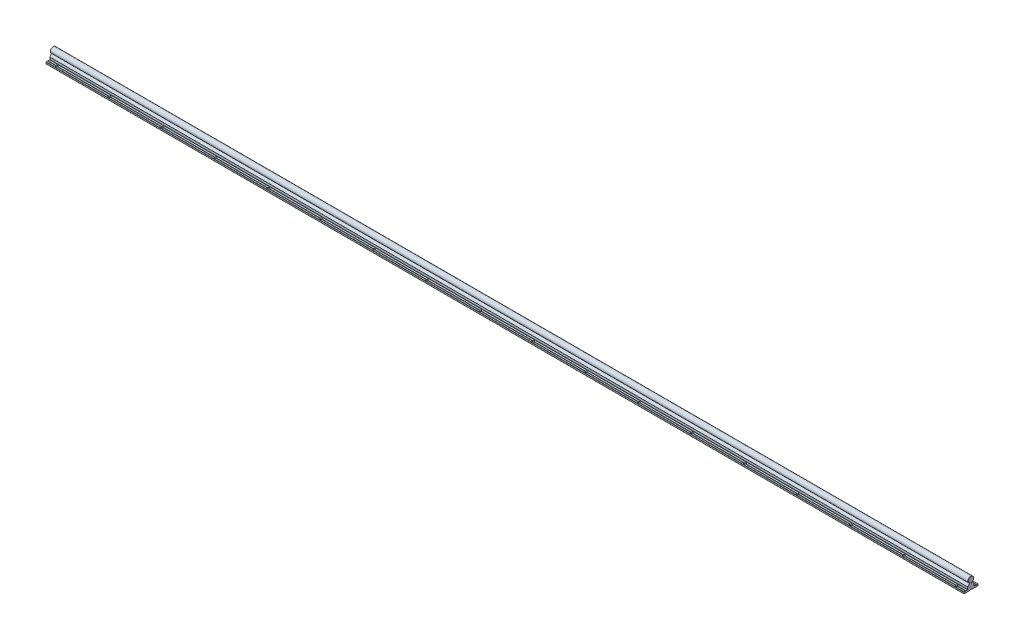
from build123d import *

# Parameters (mm, degrees)
EXTRUDE_10366_DEPTH      = 1500
SKETCH_1_3_R             = 8
EXTRUDE_10495_DEPTH      = 1500
FILLET_4_R               = 0.2
SKETCH_2_R               = 2.75
CUT_EXTRUDE_1_DEPTH      = 6
PATTERN_LINEAR_1_COUNT   = 20
PATTERN_LINEAR_1_PITCH   = 150
PATTERN_LINEAR_2_COUNT   = 20
PATTERN_LINEAR_2_PITCH   = 150
FILLET_1_R               = 0.3
CUT_EXTRUDE_2_DEPTH      = 3
FILLET_2_R               = 0.3
PATTERN_LINEAR_3_COUNT   = 20
PATTERN_LINEAR_3_PITCH   = 150
CHAMFER_1_SIZE           = 0.5
FILLET_3_R               = 0.5
FILLET_5_R               = 0.2
FILLET_6_R               = 0.1
FILLET_7_R               = 0.1
SKETCH_7_W               = 3500
SKETCH_7_H               = 1500
SKETCH_7_W_2             = 2600
SKETCH_7_H_2             = 1000
CUT_EXTRUDE_3_DEPTH      = 9.0000001
CUT_EXTRUDE_3_DEPTH_BACK = 26.0000001
CHAMFER_2_SIZE           = 0.5


with BuildPart() as part:
    # Sketch 1 → Extrude 10366 (new body, symmetric)
    with BuildSketch(Plane(origin=(0, 0, 0), x_dir=(0, 0, -1), z_dir=(1, 0, 0))):
        Polygon((-20, -25), (-4.75, -25), (-4.75, -24.4), (4.75, -24.4), (4.75, -25), (20, -25), (20, -20), (15.5, -20), (15, -20.5), (14.5, -20), (9.25, -20), (9.25, -13.3), (9.110116754, -13.3), (4, -7.21), (3.8, -7.21), (2.309327639, -7.659439004), (0, -8.355703281), (-2.309327657, -7.659438999), (-3.8, -7.21), (-4, -7.21), (-9.110116754, -13.3), (-9.25, -13.3), (-9.25, -20), (-14.5, -20), (-15, -20.5), (-15.5, -20), (-20, -20), align=None)
    extrude(amount=EXTRUDE_10366_DEPTH, both=True)

    # Fillet 4
    fillet_4_edges = [part.edges().sort_by_distance(p)[0] for p in [
        (0, -20, -15.5),
        (0, -24.4, -4.75),
        (0, -24.4, 4.75),
        (0, -20, 15.5),
        (0, -20, 14.5),
        (0, -8.355703281, 0),
        (0, -20, -14.5),
    ]]
    fillet(fillet_4_edges, radius=FILLET_4_R)

    # Sketch 2 → Cut-Extrude 1 (cut, through all)
    with BuildSketch(Plane(origin=(0, -20, 0), x_dir=(1, 0, 0), z_dir=(0, 1, 0))):
        with Locations((-1425, -15)):
            Circle(SKETCH_2_R)
        with Locations((-1425, 15)):
            Circle(SKETCH_2_R)
        with Locations((-1275, -15)):
            Circle(SKETCH_2_R)
        with Locations((-1275, 15)):
            Circle(SKETCH_2_R)
        with Locations((-1125, -15)):
            Circle(SKETCH_2_R)
        with Locations((-1125, 15)):
            Circle(SKETCH_2_R)
        with Locations((-975, -15)):
            Circle(SKETCH_2_R)
        with Locations((-975, 15)):
            Circle(SKETCH_2_R)
        with Locations((-825, -15)):
            Circle(SKETCH_2_R)
        with Locations((-825, 15)):
            Circle(SKETCH_2_R)
        with Locations((-675, -15)):
            Circle(SKETCH_2_R)
        with Locations((-675, 15)):
            Circle(SKETCH_2_R)
        with Locations((-525, -15)):
            Circle(SKETCH_2_R)
        with Locations((-525, 15)):
            Circle(SKETCH_2_R)
        with Locations((-375, -15)):
            Circle(SKETCH_2_R)
        with Locations((-375, 15)):
            Circle(SKETCH_2_R)
        with Locations((-225, -15)):
            Circle(SKETCH_2_R)
        with Locations((-225, 15)):
            Circle(SKETCH_2_R)
        with Locations((-75, -15)):
            Circle(SKETCH_2_R)
        with Locations((-75, 15)):
            Circle(SKETCH_2_R)
        with Locations((75, -15)):
            Circle(SKETCH_2_R)
        with Locations((75, 15)):
            Circle(SKETCH_2_R)
        with Locations((225, -15)):
            Circle(SKETCH_2_R)
        with Locations((225, 15)):
            Circle(SKETCH_2_R)
        with Locations((375, -15)):
            Circle(SKETCH_2_R)
        with Locations((375, 15)):
            Circle(SKETCH_2_R)
        with Locations((525, -15)):
            Circle(SKETCH_2_R)
        with Locations((525, 15)):
            Circle(SKETCH_2_R)
        with Locations((675, -15)):
            Circle(SKETCH_2_R)
        with Locations((675, 15)):
            Circle(SKETCH_2_R)
        with Locations((825, -15)):
            Circle(SKETCH_2_R)
        with Locations((825, 15)):
            Circle(SKETCH_2_R)
        with Locations((975, -15)):
            Circle(SKETCH_2_R)
        with Locations((975, 15)):
            Circle(SKETCH_2_R)
        with Locations((1125, -15)):
            Circle(SKETCH_2_R)
        with Locations((1125, 15)):
            Circle(SKETCH_2_R)
        with Locations((1275, -15)):
            Circle(SKETCH_2_R)
        with Locations((1275, 15)):
            Circle(SKETCH_2_R)
        with Locations((1425, -15)):
            Circle(SKETCH_2_R)
        with Locations((1425, 15)):
            Circle(SKETCH_2_R)
    extrude(amount=-CUT_EXTRUDE_1_DEPTH, mode=Mode.SUBTRACT)

    # Sketch 3 → Cut-Revolve 1 (revolve, cut)
    with BuildSketch(Plane.XY):
        Polygon((-1425, 0), (-1427.2, -1.270170592), (-1427.2, -7.5), (-1427.75, -7.5), (-1427.75, -19), (-1429.75, -19), (-1429.75, -24.4), (-1425, -24.4), align=None)
    cut_revolve_1 = revolve(axis=Axis((-1425, 56.434869358, 0), (0, -1, 0)), mode=Mode.SUBTRACT)

    # Pattern Linear 1: Cut-Revolve 1 ×20
    with Locations(*[(i * PATTERN_LINEAR_1_PITCH, 0, 0) for i in range(1, PATTERN_LINEAR_1_COUNT)]):
        add(cut_revolve_1, mode=Mode.SUBTRACT)

    # Fillet 3
    fillet_3_edges = [part.edges().sort_by_distance(p)[0] for p in [
        (0, -20, -9.25),
        (0, -20, -20),
        (0, -25, -20),
        (0, -25, -4.75),
        (0, -25, 4.75),
        (0, -20, 9.25),
        (0, -25, 20),
        (0, -20, 20),
    ]]
    fillet(fillet_3_edges, radius=FILLET_3_R)

    # Fillet 5
    fillet_5_edges = [part.edges().sort_by_distance(p)[0] for p in [
        (0, -7.21, 4),
        (0, -7.21, 3.8),
        (0, -7.21, -3.8),
        (0, -7.21, -4),
    ]]
    fillet(fillet_5_edges, radius=FILLET_5_R)

    # Fillet 6
    fillet_6_edges = [part.edges().sort_by_distance(p)[0] for p in [
        (0, -13.3, 9.25),
        (0, -13.3, -9.25),
    ]]
    fillet(fillet_6_edges, radius=FILLET_6_R)

    # Fillet 7
    fillet_7_edges = [part.edges().sort_by_distance(p)[0] for p in [
        (0, -13.3, 9.110116754),
        (0, -13.3, -9.110116754),
    ]]
    fillet(fillet_7_edges, radius=FILLET_7_R)


with BuildPart() as body_2:
    # Sketch 1_3 → Extrude 10495 (new body, symmetric)
    with BuildSketch(Plane(origin=(0, 0, 0), x_dir=(0, 0, -1), z_dir=(1, 0, 0))):
        Circle(SKETCH_1_3_R)
    extrude(amount=EXTRUDE_10495_DEPTH, both=True)

    # Sketch 4 → Cut-Revolve 2 (revolve, cut)
    with BuildSketch(Plane.XY):
        Polygon((-1425, -10), (-1427.2, -10), (-1427.2, -1.270170592), (-1425, 0), align=None)
    cut_revolve_2 = revolve(axis=Axis((-1425, 39.840222878, 0), (0, -1, 0)), mode=Mode.SUBTRACT)

    # Pattern Linear 2: Cut-Revolve 2 ×20
    with Locations(*[(i * PATTERN_LINEAR_2_PITCH, 0, 0) for i in range(1, PATTERN_LINEAR_2_COUNT)]):
        add(cut_revolve_2, mode=Mode.SUBTRACT)

    # Chamfer 1
    chamfer_1_edges = [body_2.edges().sort_by_distance(p)[0] for p in [
        (-1500, 0, 8),
        (1500, 0, 8),
    ]]
    chamfer(chamfer_1_edges, length=CHAMFER_1_SIZE)


with BuildPart() as body_3:
    # Sketch 5 → Revolve 1 (revolve)
    with BuildSketch(Plane.XY):
        Polygon((-1425, -24), (-1429.5, -24), (-1429.5, -19), (-1427.5, -19), (-1427.5, -2.461880215), (-1426.7, -2), (-1425, -2), align=None)
    revolve(axis=Axis((-1425, 35.529626596, 0), (0, -1, 0)))

    # Fillet 1
    fillet_1_edges = [body_3.edges().sort_by_distance(p)[0] for p in [
        (-1420.5, -19, 0),
    ]]
    fillet(fillet_1_edges, radius=FILLET_1_R)

    # Sketch 6 → Cut-Extrude 2 (cut)
    with BuildSketch(Plane.XZ.offset(24)):
        Polygon((-1423.25, -1.010362971), (-1423.25, 1.010362971), (-1425, 2.020725942), (-1426.75, 1.010362971), (-1426.75, -1.010362971), (-1425, -2.020725942), align=None)
    extrude(amount=-CUT_EXTRUDE_2_DEPTH, mode=Mode.SUBTRACT)

    # Fillet 2
    fillet_2_edges = [body_3.edges().sort_by_distance(p)[0] for p in [
        (-1424.125, -24, -1.515544457),
        (-1423.25, -24, 0),
        (-1424.125, -24, 1.515544457),
        (-1425.875, -24, 1.515544457),
        (-1426.75, -24, 0),
        (-1425.875, -24, -1.515544457),
        (-1420.5, -24, 0),
    ]]
    fillet(fillet_2_edges, radius=FILLET_2_R)


with BuildPart() as pattern_linear_3_1:
    # Pattern Linear 3: pattern copy
    add(body_3.part.moved(Location(Vector(1, 0, 0) * (1 * PATTERN_LINEAR_3_PITCH))))


with BuildPart() as pattern_linear_3_2:
    # Pattern Linear 3: pattern copy
    add(body_3.part.moved(Location(Vector(1, 0, 0) * (2 * PATTERN_LINEAR_3_PITCH))))


with BuildPart() as pattern_linear_3_3:
    # Pattern Linear 3: pattern copy
    add(body_3.part.moved(Location(Vector(1, 0, 0) * (3 * PATTERN_LINEAR_3_PITCH))))


with BuildPart() as pattern_linear_3_4:
    # Pattern Linear 3: pattern copy
    add(body_3.part.moved(Location(Vector(1, 0, 0) * (4 * PATTERN_LINEAR_3_PITCH))))


with BuildPart() as pattern_linear_3_5:
    # Pattern Linear 3: pattern copy
    add(body_3.part.moved(Location(Vector(1, 0, 0) * (5 * PATTERN_LINEAR_3_PITCH))))


with BuildPart() as pattern_linear_3_6:
    # Pattern Linear 3: pattern copy
    add(body_3.part.moved(Location(Vector(1, 0, 0) * (6 * PATTERN_LINEAR_3_PITCH))))


with BuildPart() as pattern_linear_3_7:
    # Pattern Linear 3: pattern copy
    add(body_3.part.moved(Location(Vector(1, 0, 0) * (7 * PATTERN_LINEAR_3_PITCH))))


with BuildPart() as pattern_linear_3_8:
    # Pattern Linear 3: pattern copy
    add(body_3.part.moved(Location(Vector(1, 0, 0) * (8 * PATTERN_LINEAR_3_PITCH))))


with BuildPart() as pattern_linear_3_9:
    # Pattern Linear 3: pattern copy
    add(body_3.part.moved(Location(Vector(1, 0, 0) * (9 * PATTERN_LINEAR_3_PITCH))))


with BuildPart() as pattern_linear_3_10:
    # Pattern Linear 3: pattern copy
    add(body_3.part.moved(Location(Vector(1, 0, 0) * (10 * PATTERN_LINEAR_3_PITCH))))


with BuildPart() as pattern_linear_3_11:
    # Pattern Linear 3: pattern copy
    add(body_3.part.moved(Location(Vector(1, 0, 0) * (11 * PATTERN_LINEAR_3_PITCH))))


with BuildPart() as pattern_linear_3_12:
    # Pattern Linear 3: pattern copy
    add(body_3.part.moved(Location(Vector(1, 0, 0) * (12 * PATTERN_LINEAR_3_PITCH))))


with BuildPart() as pattern_linear_3_13:
    # Pattern Linear 3: pattern copy
    add(body_3.part.moved(Location(Vector(1, 0, 0) * (13 * PATTERN_LINEAR_3_PITCH))))


with BuildPart() as pattern_linear_3_14:
    # Pattern Linear 3: pattern copy
    add(body_3.part.moved(Location(Vector(1, 0, 0) * (14 * PATTERN_LINEAR_3_PITCH))))


with BuildPart() as pattern_linear_3_15:
    # Pattern Linear 3: pattern copy
    add(body_3.part.moved(Location(Vector(1, 0, 0) * (15 * PATTERN_LINEAR_3_PITCH))))


with BuildPart() as pattern_linear_3_16:
    # Pattern Linear 3: pattern copy
    add(body_3.part.moved(Location(Vector(1, 0, 0) * (16 * PATTERN_LINEAR_3_PITCH))))


with BuildPart() as pattern_linear_3_17:
    # Pattern Linear 3: pattern copy
    add(body_3.part.moved(Location(Vector(1, 0, 0) * (17 * PATTERN_LINEAR_3_PITCH))))


with BuildPart() as pattern_linear_3_18:
    # Pattern Linear 3: pattern copy
    add(body_3.part.moved(Location(Vector(1, 0, 0) * (18 * PATTERN_LINEAR_3_PITCH))))


with BuildPart() as pattern_linear_3_19:
    # Pattern Linear 3: pattern copy
    add(body_3.part.moved(Location(Vector(1, 0, 0) * (19 * PATTERN_LINEAR_3_PITCH))))


with BuildPart() as cut_extrude_3_tool:
    # Sketch 7 → Cut-Extrude 3 (new body, two sides)
    with BuildSketch(Plane(origin=(0, 0, 0), x_dir=(1, 0, 0), z_dir=(0, 1, 0))) as cut_extrude_3_sk:
        Rectangle(SKETCH_7_W, SKETCH_7_H)
        Rectangle(SKETCH_7_W_2, SKETCH_7_H_2, mode=Mode.SUBTRACT)
    extrude(amount=CUT_EXTRUDE_3_DEPTH)
    extrude(cut_extrude_3_sk.sketch, amount=-CUT_EXTRUDE_3_DEPTH_BACK)


with BuildPart() as part_1:
    add(part.part)

    # Cut-Extrude 3: cut by cut_extrude_3_tool
    add(cut_extrude_3_tool.part, mode=Mode.SUBTRACT)


with BuildPart() as body_2_1:
    add(body_2.part)

    # Cut-Extrude 3: cut by cut_extrude_3_tool
    add(cut_extrude_3_tool.part, mode=Mode.SUBTRACT)

    # Chamfer 2
    chamfer_2_edges = [body_2_1.edges().sort_by_distance(p)[0] for p in [
        (-1300, 0, 8),
        (1300, 0, 8),
    ]]
    chamfer(chamfer_2_edges, length=CHAMFER_2_SIZE)


with BuildPart() as body_3_1:
    add(body_3.part)

    # Cut-Extrude 3: cut by cut_extrude_3_tool
    add(cut_extrude_3_tool.part, mode=Mode.SUBTRACT)


with BuildPart() as pattern_linear_3_19_1:
    add(pattern_linear_3_19.part)

    # Cut-Extrude 3: cut by cut_extrude_3_tool
    add(cut_extrude_3_tool.part, mode=Mode.SUBTRACT)


solid = Compound([pattern_linear_3_1.part, pattern_linear_3_2.part, pattern_linear_3_3.part, pattern_linear_3_4.part, pattern_linear_3_5.part, pattern_linear_3_6.part, pattern_linear_3_7.part, pattern_linear_3_8.part, pattern_linear_3_9.part, pattern_linear_3_10.part, pattern_linear_3_11.part, pattern_linear_3_12.part, pattern_linear_3_13.part, pattern_linear_3_14.part, pattern_linear_3_15.part, pattern_linear_3_16.part, pattern_linear_3_17.part, pattern_linear_3_18.part, part_1.part, body_2_1.part])
